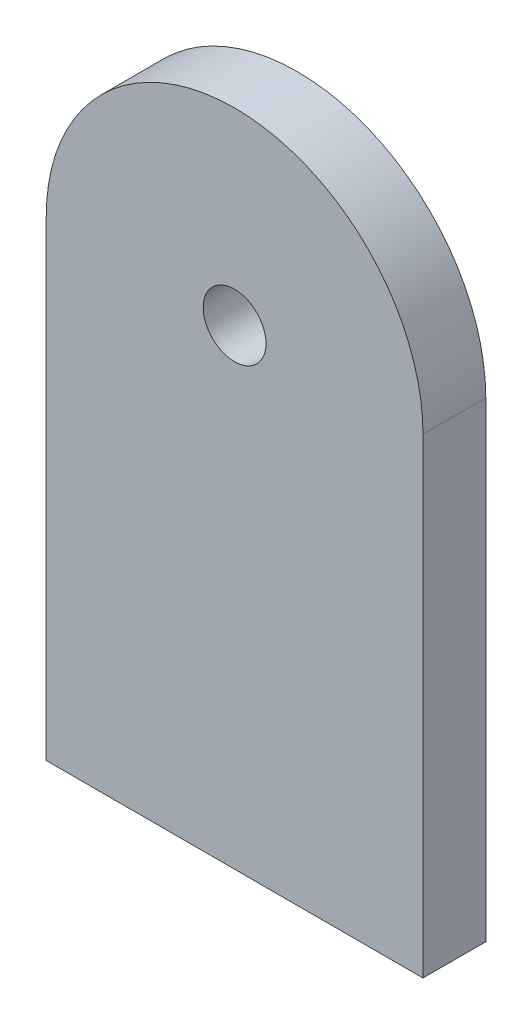
from build123d import *

# Parameters (mm, degrees)
CROQUIS1_R              = 5
SALIENTE_EXTRUIR1_DEPTH = 10


with BuildPart() as part:
    # Croquis1 → Saliente-Extruir1 (new body)
    with BuildSketch(Plane.XY):
        with BuildLine():
            Line((9.5, -75), (-30, -75))
            Line((-30, -75), (-30, 0))
            ThreePointArc((-30, 0), (0, 30), (30, 0))
            Line((30, 0), (30, -75))
            Line((30, -75), (9.5, -75))
        make_face()
        Circle(CROQUIS1_R, mode=Mode.SUBTRACT)
    extrude(amount=SALIENTE_EXTRUIR1_DEPTH)


solid = part.part
